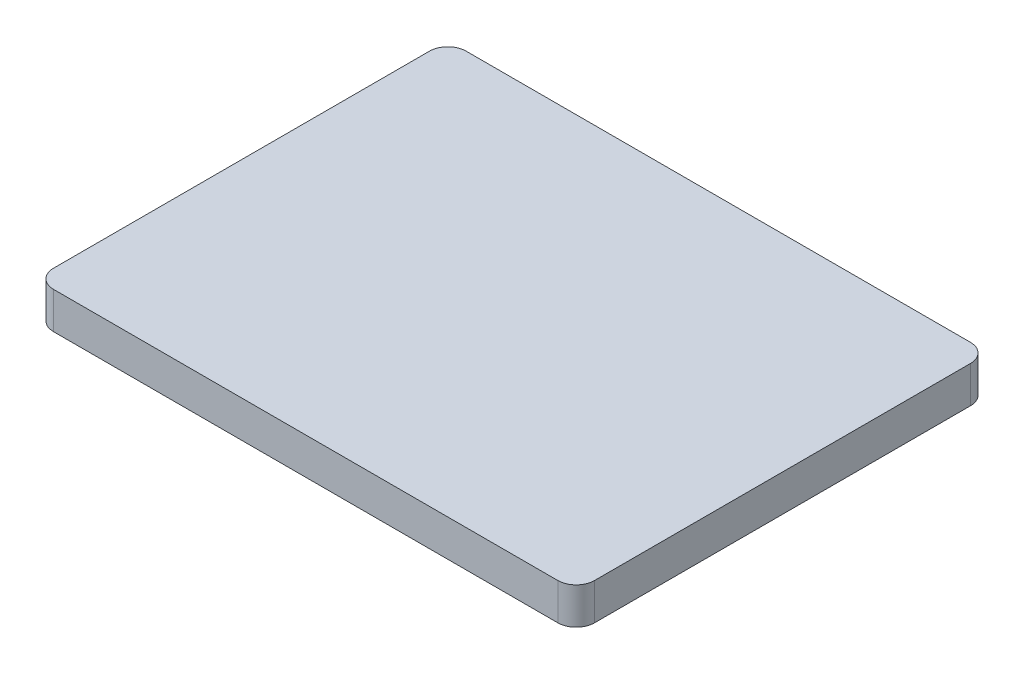
from build123d import *

# Parameters (mm, degrees)
SKETCH_2_W  = 29.5
SKETCH_2_H  = 22.5
LAYER_DEPTH = 2
FILLET_1_R  = 1


with BuildPart() as part:
    # 草图2 → layer (new body)
    with BuildSketch(Plane(origin=(0, 0, 0), x_dir=(1, 0, 0), z_dir=(0, 1, 0))):
        Rectangle(SKETCH_2_W, SKETCH_2_H)
    extrude(amount=LAYER_DEPTH)

    # 圆角1
    fillet_1_edges = [part.edges().sort_by_distance(p)[0] for p in [
        (14.75, 1, 11.25),
        (-14.75, 1, 11.25),
        (-14.75, 1, -11.25),
        (14.75, 1, -11.25),
    ]]
    fillet(fillet_1_edges, radius=FILLET_1_R)


solid = part.part
